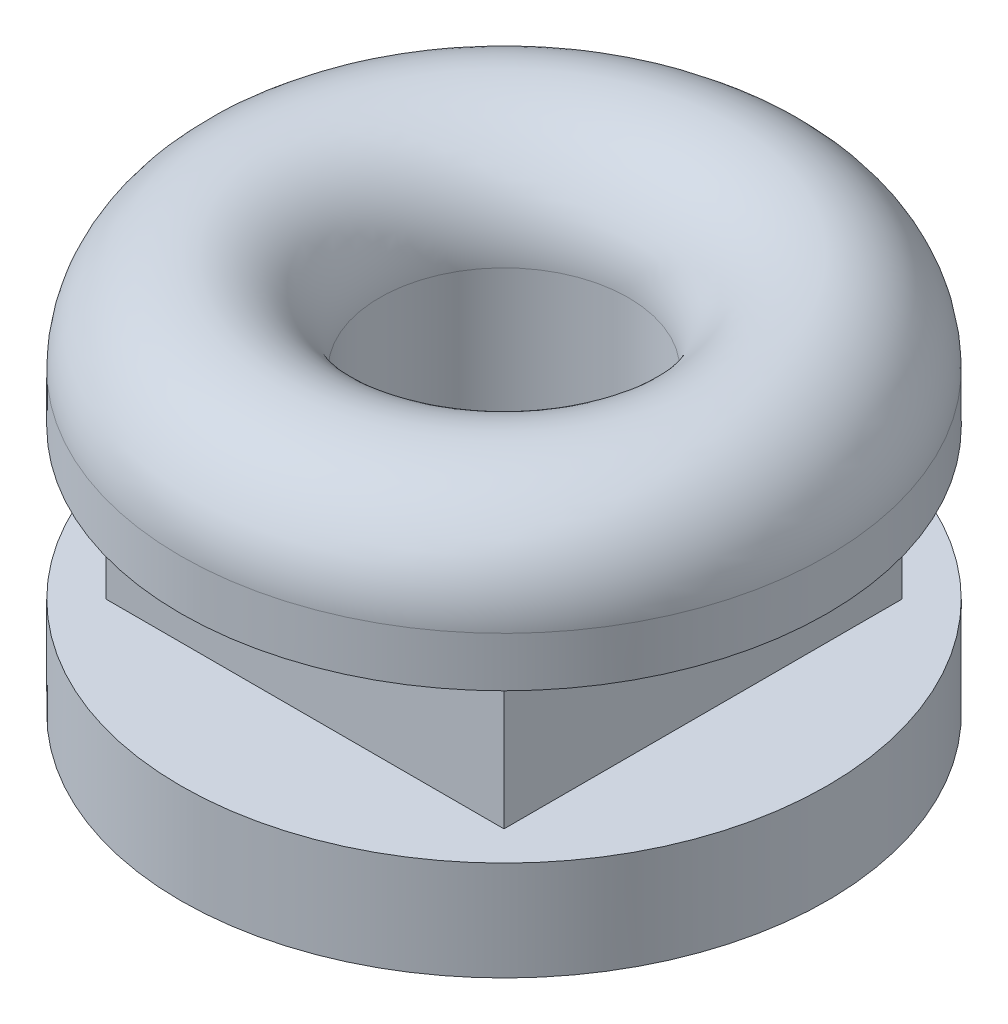
from build123d import *

# Parameters (mm, degrees)
SKETCH3_R          = 6.5
SKETCH3_W          = 8
SKETCH3_H          = 8
CUT_EXTRUDE1_DEPTH = 3


with BuildPart() as part:
    # Sketch1 → Revolve1 (revolve)
    with BuildSketch(Plane.XY):
        with BuildLine():
            Line((-2.5, -5), (-2.5, 1))
            ThreePointArc((-2.5, 1), (-4.5, 3), (-6.5, 1))
            Line((-6.5, 1), (-6.5, -5))
            Line((-6.5, -5), (-2.5, -5))
        make_face()
    revolve(axis=Axis((0, 0, 0), (0, -1, 0)))

    # Sketch3 → Cut-Extrude1 (cut)
    with BuildSketch(Plane(origin=(0, -3, 0), x_dir=(-1, 0, 0), z_dir=(0, -1, 0))):
        Circle(SKETCH3_R)
        Rectangle(SKETCH3_W, SKETCH3_H, mode=Mode.SUBTRACT)
    extrude(amount=-CUT_EXTRUDE1_DEPTH, mode=Mode.SUBTRACT)


solid = part.part
